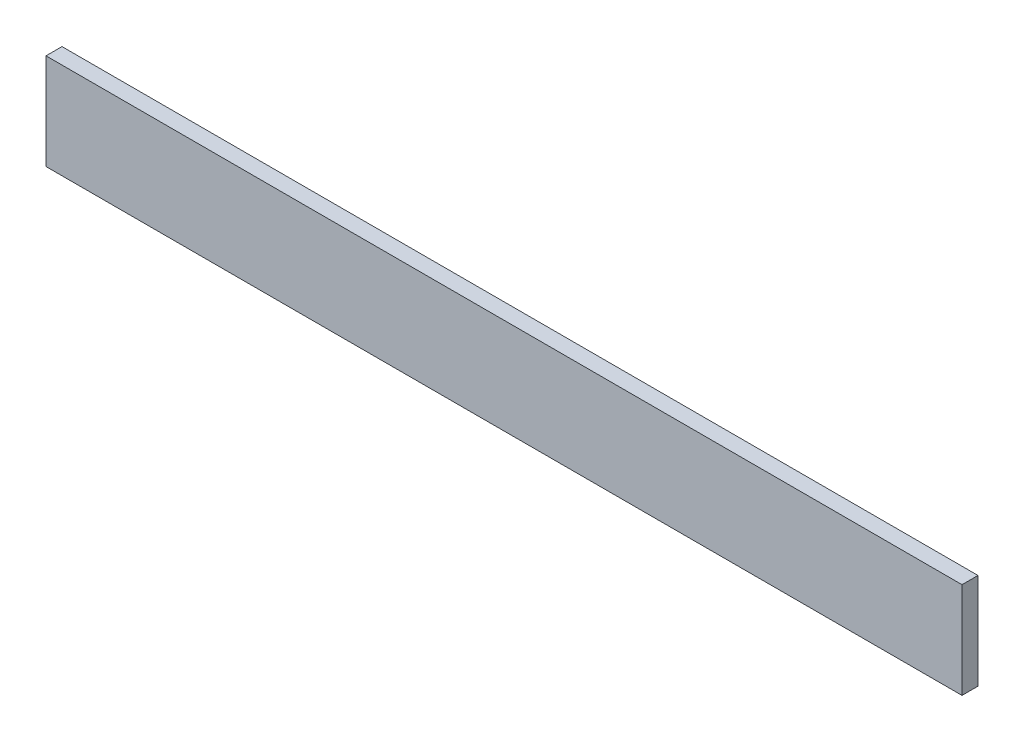
from build123d import *

# Parameters (mm, degrees)
SKETCH1_W           = 286.5
SKETCH1_H           = 30
BOSS_EXTRUDE1_DEPTH = 5


with BuildPart() as part:
    # Sketch1 → Boss-Extrude1 (new body)
    with BuildSketch(Plane.XY):
        Rectangle(SKETCH1_W, SKETCH1_H)
    extrude(amount=BOSS_EXTRUDE1_DEPTH)


solid = part.part
